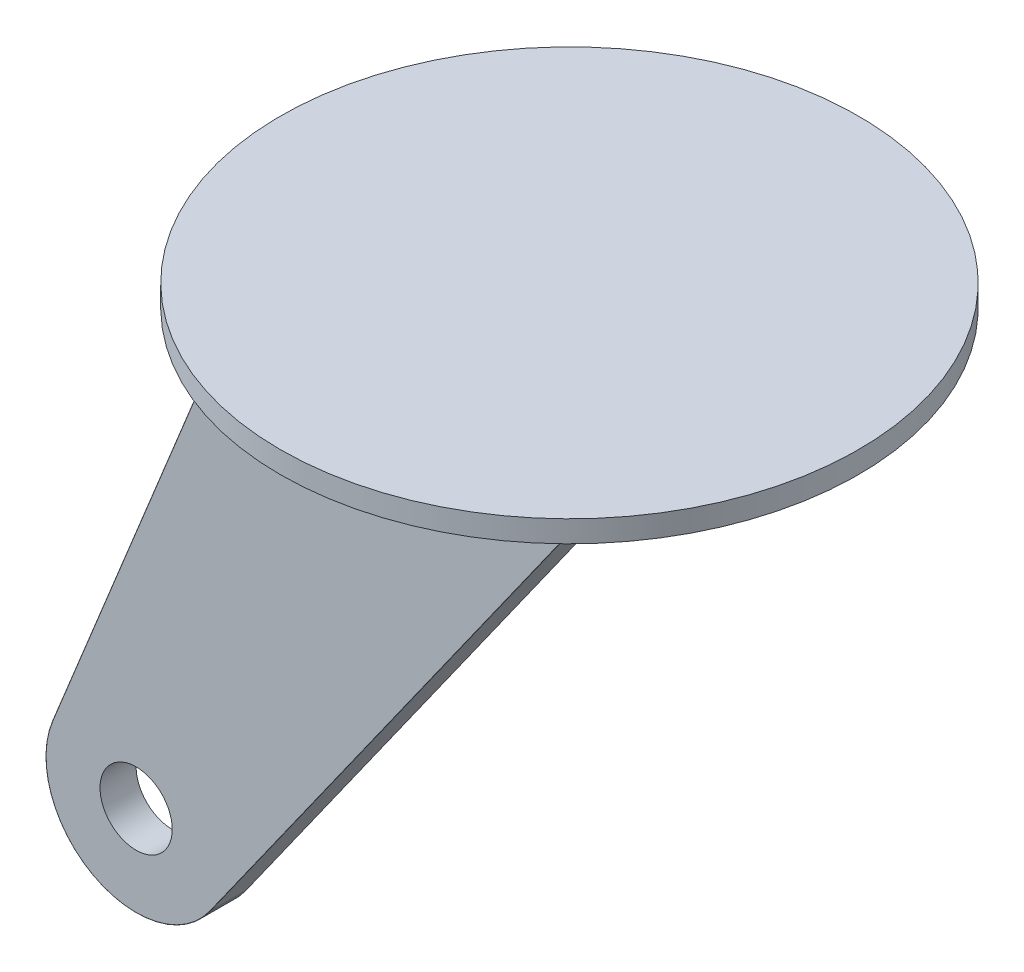
from build123d import *

# Parameters (mm, degrees)
SKETCH1_R           = 1016
BOSS_EXTRUDE1_DEPTH = 76.2
SKETCH2_R           = 127
BOSS_EXTRUDE3_DEPTH = 127
FILLET1_R           = 1


with BuildPart() as part:
    # Sketch1 → Boss-Extrude1 (new body)
    with BuildSketch(Plane(origin=(0, 0, 0), x_dir=(1, 0, 0), z_dir=(0, 1, 0))):
        Circle(SKETCH1_R)
    extrude(amount=BOSS_EXTRUDE1_DEPTH)

    # Sketch2 → Boss-Extrude3 (add)
    with BuildSketch(Plane.XY.offset(381)):
        with BuildLine():
            Line((0, 0), (635, 0))
            Line((635, 0), (-756.363558902, -1961.682110671))
            ThreePointArc((-756.363558902, -1961.682110671), (-1167.996982196, -2056.390219688), (-1309.445120969, -1658.390062497))
            Line((-1309.445120969, -1658.390062497), (-635, 0))
            Line((-635, 0), (0, 0))
        make_face()
        with Locations((-1015.336785741, -1778)):
            Circle(SKETCH2_R, mode=Mode.SUBTRACT)
    extrude(amount=BOSS_EXTRUDE3_DEPTH)

    # Fillet1
    fillet1_edges = [part.edges().sort_by_distance(p)[0] for p in [
        (-972.222560484, -829.195031249, 508),
        (-1167.996982196, -2056.390219688, 508),
        (-60.681779451, -980.841055336, 508),
        (-972.222560484, -829.195031249, 381),
        (-1167.996982196, -2056.390219688, 381),
        (-60.681779451, -980.841055336, 381),
    ]]
    fillet(fillet1_edges, radius=FILLET1_R)


solid = part.part
